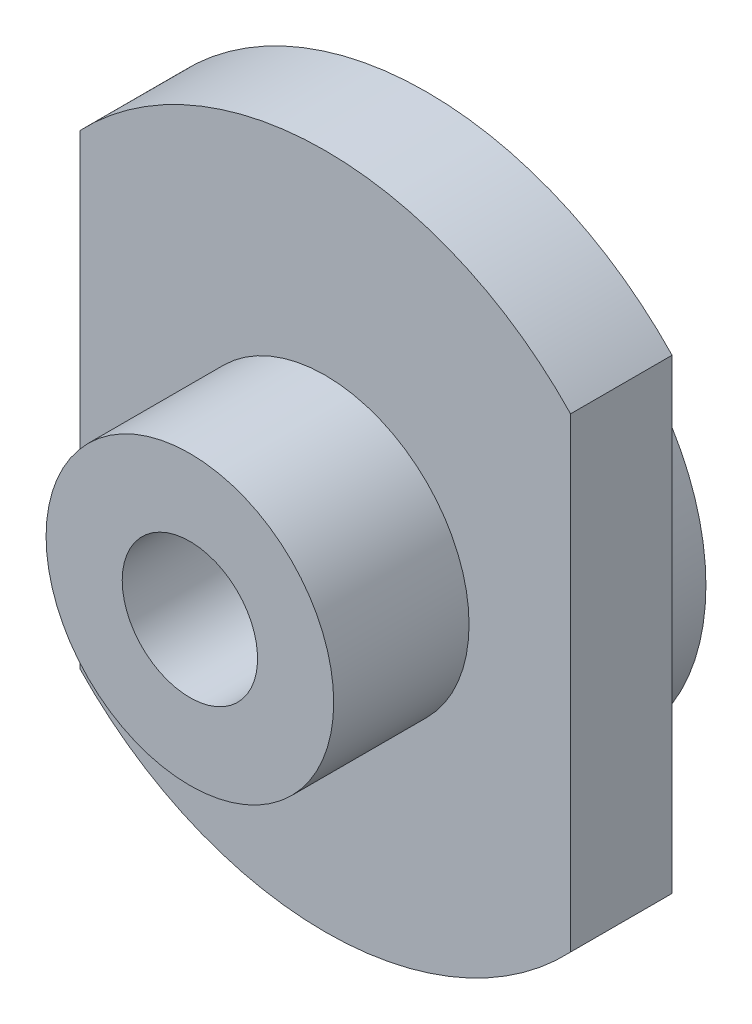
from build123d import *

# Parameters (mm, degrees)
SKETCH_1_R           = 17
EXTRUDE_1_DEPTH      = 34
EXTRUDE_START        = 6
SKETCH_2_R           = 40
EXTRUDE_2_DEPTH      = 12
SKETCH_3_R           = 27
EXTRUDE_3_DEPTH      = 6
SKETCH_4_R           = 24
SKETCH_4_R_2         = 12
CUT_EXTRUDE_1_DEPTH  = 9
SKETCH_5_OUTSIDE_W   = 105.628
SKETCH_5_OUTSIDE_H   = 105.628
SKETCH_5_OUTSIDE_W_2 = 58
SKETCH_5_OUTSIDE_H_2 = 80
SKETCH_5_OUTSIDE_R   = 8
CUT_EXTRUDE_2_DEPTH  = 35


with BuildPart() as part:
    # 草圖1 → 填料-伸長1 (new body)
    with BuildSketch(Plane.XY):
        Circle(SKETCH_1_R)
    extrude(amount=EXTRUDE_1_DEPTH)

    # 草圖2 → 填料-伸長2 (add)
    with BuildSketch(Plane.XY.offset(EXTRUDE_START)):
        Circle(SKETCH_2_R)
    extrude(amount=EXTRUDE_2_DEPTH)

    # 草圖3 → 填料-伸長3 (add)
    with BuildSketch(Plane(origin=(0, 0, 6), x_dir=(-1, 0, 0), z_dir=(0, 0, -1))):
        Circle(SKETCH_3_R)
    extrude(amount=EXTRUDE_3_DEPTH)

    # 草圖4 → 除料-伸長1 (cut)
    with BuildSketch(Plane(origin=(0, 0, 0), x_dir=(-1, 0, 0), z_dir=(0, 0, -1))):
        Circle(SKETCH_4_R)
        Circle(SKETCH_4_R_2, mode=Mode.SUBTRACT)
    extrude(amount=-CUT_EXTRUDE_1_DEPTH, mode=Mode.SUBTRACT)

    # 草圖5 outside → 除料-伸長2 (cut, through all)
    with BuildSketch(Plane(origin=(0, 0, 0), x_dir=(-1, 0, 0), z_dir=(0, 0, -1))):
        Rectangle(SKETCH_5_OUTSIDE_W, SKETCH_5_OUTSIDE_H)
        Rectangle(SKETCH_5_OUTSIDE_W_2, SKETCH_5_OUTSIDE_H_2, mode=Mode.SUBTRACT)
        Circle(SKETCH_5_OUTSIDE_R)
    extrude(amount=-CUT_EXTRUDE_2_DEPTH, mode=Mode.SUBTRACT)


solid = part.part
